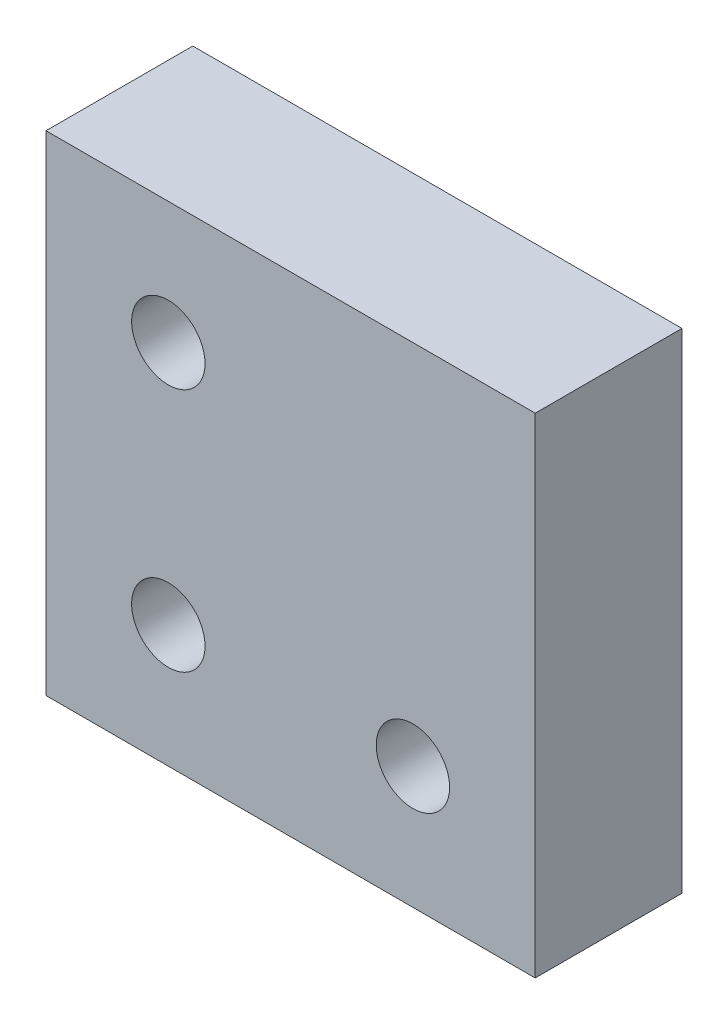
from build123d import *

# Parameters (mm, degrees)
ESQUISSE1_W             = 20
ESQUISSE1_H             = 20
BOSS_EXTRU_1_DEPTH      = 6
ESQUISSE2_R             = 1.5
ENL_V_MAT_EXTRU_1_DEPTH = 6


with BuildPart() as part:
    # Esquisse1 → Boss.-Extru.1 (new body)
    with BuildSketch(Plane.XY):
        Rectangle(ESQUISSE1_W, ESQUISSE1_H)
    extrude(amount=BOSS_EXTRU_1_DEPTH)

    # Esquisse2 → Enlèv. mat.-Extru.1 (cut)
    with BuildSketch(Plane.XY.offset(6)):
        with Locations((-5, 5)):
            Circle(ESQUISSE2_R)
        with Locations((-5, -5)):
            Circle(ESQUISSE2_R)
        with Locations((5, -5)):
            Circle(ESQUISSE2_R)
    extrude(amount=-ENL_V_MAT_EXTRU_1_DEPTH, mode=Mode.SUBTRACT)


solid = part.part
